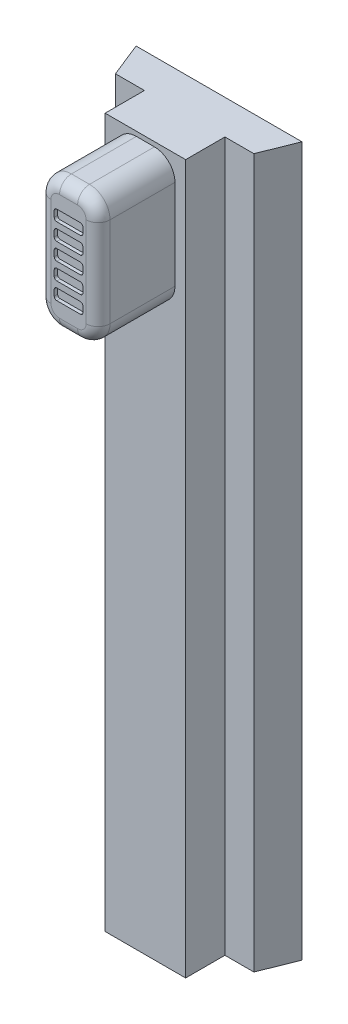
from build123d import *

# Parameters (mm, degrees)
BOSS_EXTRUDE1_DEPTH        = 41.5
SKETCH2_W                  = 3.459033884
SKETCH2_H                  = 7.669300129
BOSS_EXTRUDE2_DEPTH        = 4.5
FILLET1_R                  = 1.2
FILLET2_R                  = 0.7
SKETCH3_W                  = 1.676518228
SKETCH3_H                  = 0.644745983
CUT_EXTRUDE1_DEPTH         = 0.2
FILLET3_R                  = 0.15
LPATTERN1_COUNT            = 3
LPATTERN1_PITCH            = 1
FILLET3_OF_LPATTERN1_R     = 0.15
LPATTERN1_COL_COUNT        = 3
LPATTERN1_COL_PITCH        = 1
FILLET3_OF_LPATTERN1_COL_R = 0.15


with BuildPart() as part:
    # Sketch1 → Boss-Extrude1 (new body)
    with BuildSketch(Plane(origin=(0, 0, 0), x_dir=(1, 0, 0), z_dir=(0, 1, 0))):
        Polygon((0.878746859, -0.34499804), (5.591575223, -0.34499804), (5.591575223, 1.95500196), (7.288815202, 1.95500196), (8.091575223, 3.966300559), (-1.621253141, 3.966300559), (-0.81849312, 1.95500196), (0.878746859, 1.95500196), align=None)
    extrude(amount=BOSS_EXTRUDE1_DEPTH)

    # Sketch2 → Boss-Extrude2 (add)
    with BuildSketch(Plane.XY.offset(0.34499804)):
        with Locations((3.235161041, 37.399269449)):
            Rectangle(SKETCH2_W, SKETCH2_H)
    extrude(amount=BOSS_EXTRUDE2_DEPTH)

    # Fillet1
    fillet1_edges = [part.edges().sort_by_distance(p)[0] for p in [
        (1.505644099, 41.233919514, 2.59499804),
        (1.505644099, 33.564619385, 2.59499804),
        (4.964677983, 33.564619385, 2.59499804),
        (4.964677983, 41.233919514, 2.59499804),
    ]]
    fillet(fillet1_edges, radius=FILLET1_R)

    # Fillet2
    fillet2_edges = [part.edges().sort_by_distance(p)[0] for p in [
        (3.235161041, 41.233919514, 4.84499804),
        (4.964677983, 37.399269449, 4.84499804),
        (1.505644099, 37.399269449, 4.84499804),
        (3.235161041, 33.564619385, 4.84499804),
        (4.613206121, 33.916091248, 4.84499804),
        (1.857115961, 33.916091248, 4.84499804),
        (1.857115961, 40.882447651, 4.84499804),
        (4.613206121, 40.882447651, 4.84499804),
    ]]
    fillet(fillet2_edges, radius=FILLET2_R)

    # Sketch3 → Cut-Extrude1 (cut)
    with BuildSketch(Plane.XY.offset(4.84499804)):
        with Locations((3.235161041, 37.399269449)):
            Rectangle(SKETCH3_W, SKETCH3_H)
    cut_extrude1 = extrude(amount=-CUT_EXTRUDE1_DEPTH, mode=Mode.SUBTRACT)

    # Fillet3
    fillet3_edges = [part.edges().sort_by_distance(p)[0] for p in [
        (2.396901927, 37.076896458, 4.74499804),
        (2.396901927, 37.721642441, 4.74499804),
        (4.073420155, 37.721642441, 4.74499804),
        (4.073420155, 37.076896458, 4.74499804),
    ]]
    fillet(fillet3_edges, radius=FILLET3_R)

    # LPattern1: Cut-Extrude1 ×3
    with Locations(*[(0, i * LPATTERN1_PITCH, 0) for i in range(1, LPATTERN1_COUNT)]):
        add(cut_extrude1, mode=Mode.SUBTRACT)

    # Fillet3 of LPattern1
    fillet3_of_lpattern1_edges = [part.edges().sort_by_distance(p)[0] for p in [
        (2.396901927, 38.076896458, 4.74499804),
        (2.396901927, 38.721642441, 4.74499804),
        (4.073420155, 38.721642441, 4.74499804),
        (4.073420155, 38.076896458, 4.74499804),
        (2.396901927, 39.076896458, 4.74499804),
        (2.396901927, 39.721642441, 4.74499804),
        (4.073420155, 39.721642441, 4.74499804),
        (4.073420155, 39.076896458, 4.74499804),
    ]]
    fillet(fillet3_of_lpattern1_edges, radius=FILLET3_OF_LPATTERN1_R)

    # LPattern1 col: Cut-Extrude1 ×3
    with Locations(*[(0, -i * LPATTERN1_COL_PITCH, 0) for i in range(1, LPATTERN1_COL_COUNT)]):
        add(cut_extrude1, mode=Mode.SUBTRACT)

    # Fillet3 of LPattern1 col
    fillet3_of_lpattern1_col_edges = [part.edges().sort_by_distance(p)[0] for p in [
        (2.396901927, 36.076896458, 4.74499804),
        (2.396901927, 36.721642441, 4.74499804),
        (4.073420155, 36.721642441, 4.74499804),
        (4.073420155, 36.076896458, 4.74499804),
        (2.396901927, 35.076896458, 4.74499804),
        (2.396901927, 35.721642441, 4.74499804),
        (4.073420155, 35.721642441, 4.74499804),
        (4.073420155, 35.076896458, 4.74499804),
    ]]
    fillet(fillet3_of_lpattern1_col_edges, radius=FILLET3_OF_LPATTERN1_COL_R)


solid = part.part
